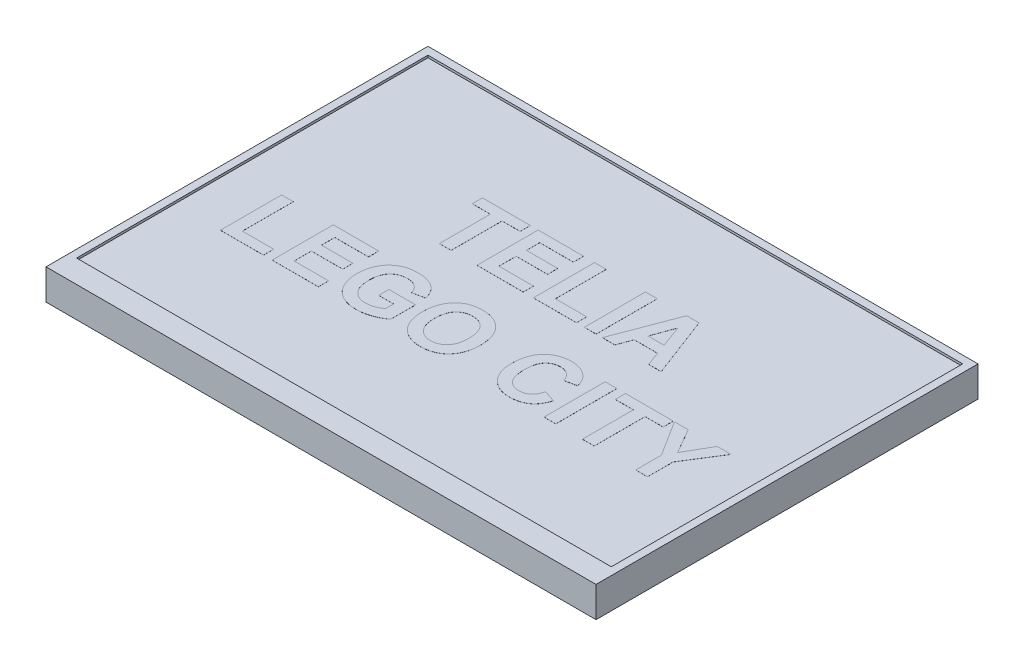
from build123d import *

# Parameters (mm, degrees)
SKETCH1_W           = 720
SKETCH1_H           = 500
BOSS_EXTRUDE1_DEPTH = 40
SKETCH2_W           = 700
SKETCH2_H           = 460
CUT_EXTRUDE1_DEPTH  = 3
SKETCH3_W           = 15.384615384
SKETCH3_H           = 80
SKETCH3_W_2         = 15.384615385
BOSS_EXTRUDE2_DEPTH = 0.1


with BuildPart() as part:
    # Sketch1 → Boss-Extrude1 (new body)
    with BuildSketch(Plane(origin=(0, 0, 0), x_dir=(1, 0, 0), z_dir=(0, 1, 0))):
        Rectangle(SKETCH1_W, SKETCH1_H)
    extrude(amount=BOSS_EXTRUDE1_DEPTH)

    # Sketch2 → Cut-Extrude1 (cut)
    with BuildSketch(Plane(origin=(0, 40, 0), x_dir=(1, 0, 0), z_dir=(0, 1, 0))):
        with Locations((0, 10)):
            Rectangle(SKETCH2_W, SKETCH2_H)
    extrude(amount=-CUT_EXTRUDE1_DEPTH, mode=Mode.SUBTRACT)

    # Sketch3 → Boss-Extrude2 (add)
    with BuildSketch(Plane(origin=(0, 37, 0), x_dir=(1, 0, 0), z_dir=(0, 1, 0))):
        Polygon((-131.794871795, 36.78780953), (-131.794871795, 103.454476196), (-155.384615385, 103.454476196), (-155.384615385, 116.78780953), (-92.820512821, 116.78780953), (-92.820512821, 103.454476196), (-116.41025641, 103.454476196), (-116.41025641, 36.78780953), align=None)
        Polygon((-82.564102564, 36.78780953), (-82.564102564, 116.78780953), (-23.076923077, 116.78780953), (-23.076923077, 103.454476196), (-67.179487179, 103.454476196), (-67.179487179, 86.018578761), (-26.153846154, 86.018578761), (-26.153846154, 72.685245427), (-67.179487179, 72.685245427), (-67.179487179, 50.121142863), (-22.051282051, 50.121142863), (-22.051282051, 36.78780953), align=None)
        Polygon((-8.717948718, 36.78780953), (-8.717948718, 116.78780953), (6.666666667, 116.78780953), (6.666666667, 50.121142863), (47.692307692, 50.121142863), (47.692307692, 36.78780953), align=None)
        with Locations((65.641025641, 76.78780953)):
            Rectangle(SKETCH3_W, SKETCH3_H)
        Polygon((158.461538462, 36.78780953), (142.147435897, 36.78780953), (135.400641026, 55.249347991), (104.695512821, 55.249347991), (97.948717949, 36.78780953), (81.538461538, 36.78780953), (111.778846154, 116.78780953), (128.076923077, 116.78780953), align=None)
        Polygon((130.512820513, 68.582681325), (120, 97.300630043), (109.519230769, 68.582681325), align=None, mode=Mode.SUBTRACT)
        Polygon((-290.256410256, -91.39167765), (-290.256410256, -11.39167765), (-274.871794872, -11.39167765), (-274.871794872, -78.058344316), (-233.846153846, -78.058344316), (-233.846153846, -91.39167765), align=None)
        Polygon((-222.564102564, -91.39167765), (-222.564102564, -11.39167765), (-163.076923077, -11.39167765), (-163.076923077, -24.725010983), (-207.179487179, -24.725010983), (-207.179487179, -42.160908419), (-166.153846154, -42.160908419), (-166.153846154, -55.494241752), (-207.179487179, -55.494241752), (-207.179487179, -78.058344316), (-162.051282051, -78.058344316), (-162.051282051, -91.39167765), align=None)
        with BuildLine():
            Line((-112.820512821, -61.648087906), (-112.820512821, -48.314754573))
            Line((-112.820512821, -48.314754573), (-77.948717949, -48.314754573))
            Line((-77.948717949, -48.314754573), (-77.948717949, -80.446164829))
            add(Edge.make_bspline(
                [(-77.948717949, -80.446164829), (-78.387588953, -80.841385134), (-79.284730078, -81.649295398), (-80.748716128, -82.788301933), (-82.359571985, -83.877201411), (-84.113983484, -84.931746637), (-85.996424546, -85.972536531), (-88.022146795, -86.96989818), (-90.196315106, -87.905457753), (-93.240000689, -89.1475945), (-97.186360379, -90.442028348), (-101.99725404, -91.588498601), (-106.849149891, -92.286681998), (-110.093934983, -92.373801468), (-111.71474359, -92.417318675)],
                knots=[0, 0, 0, 0, 0.001771395, 0.00362109, 0.005559067, 0.007601126, 0.009760072, 0.012010519, 0.01437157, 0.016859418, 0.021871449, 0.026811949, 0.031682399, 0.036543349, 0.036543349, 0.036543349, 0.036543349], degree=3))
            add(Edge.make_bspline(
                [(-111.71474359, -92.417318675), (-112.730152148, -92.402060035), (-114.731824423, -92.371980717), (-117.686748808, -92.129873694), (-120.539446606, -91.715629714), (-123.292242552, -91.129040359), (-125.954454646, -90.42192012), (-128.514985885, -89.519878819), (-130.964745565, -88.43705028), (-133.325928579, -87.230461507), (-135.554516769, -85.844596082), (-137.652663032, -84.328582969), (-139.605181332, -82.669235691), (-141.405071944, -80.863209462), (-143.076438101, -78.922942751), (-144.599778723, -76.839183168), (-145.965881588, -74.609525066), (-147.191609398, -72.261937072), (-148.282067348, -69.817065566), (-149.202222801, -67.294152925), (-150.008924634, -64.729829087), (-150.671945374, -62.115091282), (-151.15890168, -59.44143857), (-151.53745154, -56.721241772), (-151.740769537, -53.937504936), (-151.776715249, -52.065041936), (-151.794871795, -51.119241752)],
                knots=[0, 0, 0, 0, 0.003045926, 0.006004426, 0.00888726, 0.011687715, 0.014443986, 0.017145483, 0.019822197, 0.022474186, 0.025093631, 0.027686914, 0.030233429, 0.032771761, 0.035328692, 0.037909019, 0.040506409, 0.043165796, 0.045848979, 0.048531204, 0.051217591, 0.053911138, 0.056617385, 0.059366565, 0.062146817, 0.064984487, 0.064984487, 0.064984487, 0.064984487], degree=3))
            add(Edge.make_bspline(
                [(-151.794871795, -51.119241752), (-151.780147064, -50.098422477), (-151.751118255, -48.085946502), (-151.500930597, -45.111530404), (-151.11241876, -42.224275722), (-150.523265975, -39.429424141), (-149.806502281, -36.713965807), (-148.931732918, -34.07968898), (-147.859947368, -31.546111061), (-146.667683438, -29.091564395), (-145.310450407, -26.749992832), (-143.776853432, -24.551430861), (-142.112275797, -22.473703572), (-140.283824116, -20.549813915), (-138.297937308, -18.780699363), (-136.17480294, -17.146794745), (-133.919505436, -15.619933539), (-132.305328056, -14.759017355), (-131.490384615, -14.324369957)],
                knots=[0, 0, 0, 0, 0.003061946, 0.006036419, 0.008948724, 0.011796242, 0.014598943, 0.017371008, 0.020115092, 0.022845759, 0.025553144, 0.028224864, 0.030880338, 0.03353286, 0.036177285, 0.038850638, 0.041566358, 0.044335457, 0.044335457, 0.044335457, 0.044335457], degree=3))
            add(Edge.make_bspline(
                [(-131.490384615, -14.324369957), (-130.843642986, -14.003238666), (-129.530057668, -13.350994663), (-127.440137947, -12.572261151), (-125.254371351, -11.863689293), (-122.939757576, -11.335007784), (-120.512014689, -10.900655079), (-117.972218599, -10.576513868), (-115.312198451, -10.406294829), (-113.504493053, -10.379657529), (-112.580128205, -10.366036624)],
                knots=[0, 0, 0, 0, 0.002164826, 0.00439694, 0.006682771, 0.009053917, 0.011512168, 0.014080324, 0.016730425, 0.019503601, 0.019503601, 0.019503601, 0.019503601], degree=3))
            add(Edge.make_bspline(
                [(-112.580128205, -10.366036624), (-111.388328209, -10.383788597), (-109.070497579, -10.418312903), (-105.691274046, -10.705989207), (-102.510983114, -11.20178986), (-99.525195989, -11.884642284), (-96.740344999, -12.762609257), (-94.161224195, -13.841963625), (-91.772003551, -15.100983679), (-89.607288019, -16.590127438), (-87.623082655, -18.23208269), (-85.824565185, -20.028846671), (-84.211011695, -21.983080755), (-82.781354708, -24.084951761), (-81.546846576, -26.34314761), (-80.485405363, -28.737073045), (-79.611710743, -31.284901976), (-79.189473499, -33.054324018), (-78.974358974, -33.955780214)],
                knots=[0, 0, 0, 0, 0.003575011, 0.006952736, 0.010164468, 0.013223855, 0.016133027, 0.018912864, 0.021601401, 0.024219473, 0.026780218, 0.02931855, 0.031834167, 0.034372196, 0.03693274, 0.03954433, 0.04222018, 0.044999277, 0.044999277, 0.044999277, 0.044999277], degree=3))
            Line((-78.974358974, -33.955780214), (-94.358974359, -37.032703291))
            add(Edge.make_bspline(
                [(-94.358974359, -37.032703291), (-94.511311249, -36.52786343), (-94.81186909, -35.531823805), (-95.39452015, -34.102074595), (-96.065606245, -32.758015774), (-96.826737114, -31.489918891), (-97.685580572, -30.305590941), (-98.662886177, -29.217807276), (-99.697175627, -28.176949717), (-100.855997668, -27.255466686), (-102.091209354, -26.424753928), (-103.38889249, -25.675665927), (-104.778369197, -25.068176442), (-106.240176462, -24.579385067), (-107.767169576, -24.164272216), (-109.379276381, -23.908976219), (-111.058393221, -23.716433701), (-112.205595238, -23.705118794), (-112.788461538, -23.699369957)],
                knots=[0, 0, 0, 0, 0.001581269, 0.003119814, 0.00462486, 0.006084249, 0.007552324, 0.009005629, 0.010467481, 0.011949138, 0.013438143, 0.014930938, 0.016437689, 0.01797832, 0.019552589, 0.021178145, 0.022870046, 0.024617502, 0.024617502, 0.024617502, 0.024617502], degree=3))
            add(Edge.make_bspline(
                [(-112.788461538, -23.699369957), (-113.670650087, -23.722907036), (-115.392316211, -23.768841652), (-117.905719314, -24.068574894), (-120.276884559, -24.60182782), (-122.512012399, -25.337348557), (-124.615200484, -26.281440933), (-126.55802821, -27.469317606), (-128.388870833, -28.830690119), (-130.055628977, -30.42847871), (-131.567189238, -32.220056256), (-132.875715027, -34.226792461), (-133.965057143, -36.442200708), (-134.857290427, -38.855156789), (-135.567698493, -41.4657613), (-136.049630335, -44.283255853), (-136.364515831, -47.303318075), (-136.39469664, -49.38762322), (-136.41025641, -50.46219047)],
                knots=[0, 0, 0, 0, 0.002646609, 0.005165083, 0.007579483, 0.009925858, 0.012213712, 0.014478379, 0.016744407, 0.019045468, 0.021388721, 0.023762302, 0.026213387, 0.028779292, 0.0314695, 0.03431765, 0.037345817, 0.040568406, 0.040568406, 0.040568406, 0.040568406], degree=3))
            add(Edge.make_bspline(
                [(-136.41025641, -50.46219047), (-136.39403074, -51.616738414), (-136.362495203, -53.860669741), (-136.055863559, -57.111981186), (-135.551451829, -60.141167771), (-134.827959887, -62.944408614), (-133.917581702, -65.531649195), (-132.823266419, -67.911154557), (-131.472749106, -70.038770327), (-129.951506806, -71.957143992), (-128.251222093, -73.633406878), (-126.419574288, -75.094818588), (-124.466760932, -76.333312013), (-122.374774144, -77.329337897), (-120.169998631, -78.122200159), (-117.832165098, -78.678051655), (-115.368234604, -79.023326132), (-113.681719932, -79.063480692), (-112.820512821, -79.083985342)],
                knots=[0, 0, 0, 0, 0.003462874, 0.006730297, 0.00978645, 0.012666655, 0.015403711, 0.018006089, 0.020504908, 0.022945124, 0.025336169, 0.02765125, 0.029963223, 0.032256906, 0.034588623, 0.036979077, 0.039453989, 0.042036554, 0.042036554, 0.042036554, 0.042036554], degree=3))
            add(Edge.make_bspline(
                [(-112.820512821, -79.083985342), (-111.948238001, -79.059738836), (-110.195343851, -79.011013874), (-107.569833902, -78.598119121), (-104.934051389, -77.990531213), (-102.349855271, -77.073973562), (-99.840166286, -76.022688379), (-97.49710359, -74.811100784), (-95.302897566, -73.548179504), (-93.981729934, -72.563860022), (-93.333333333, -72.080780214)],
                knots=[0, 0, 0, 0, 0.002615324, 0.005255667, 0.007957164, 0.010719205, 0.013469506, 0.016114174, 0.018628974, 0.021052664, 0.021052664, 0.021052664, 0.021052664], degree=3))
            Line((-93.333333333, -72.080780214), (-93.333333333, -61.648087906))
            Line((-93.333333333, -61.648087906), (-112.820512821, -61.648087906))
        make_face()
        with BuildLine():
            add(Edge.make_bspline(
                [(-65.641025641, -51.87244688), (-65.635364368, -50.883839897), (-65.624246358, -48.942343393), (-65.43159705, -46.094095135), (-65.177670254, -43.36394283), (-64.764150876, -40.762625178), (-64.277701115, -38.277967119), (-63.669281571, -35.910706181), (-62.93635147, -33.669144284), (-62.353299774, -32.237931241), (-62.067307692, -31.535908419)],
                knots=[0, 0, 0, 0, 0.002965133, 0.005823139, 0.008561086, 0.011187972, 0.013721138, 0.016154346, 0.01851594, 0.020789549, 0.020789549, 0.020789549, 0.020789549], degree=3))
            add(Edge.make_bspline(
                [(-62.067307692, -31.535908419), (-61.599819175, -30.537901661), (-60.67034057, -28.553626336), (-58.944152715, -25.749685784), (-56.987620558, -23.105342656), (-54.816851694, -20.634459684), (-52.487266538, -18.374234629), (-49.987875189, -16.439807425), (-47.407473519, -14.765848358), (-45.572222113, -13.923946441), (-44.663461538, -13.507062265)],
                knots=[0, 0, 0, 0, 0.003304004, 0.006569147, 0.009857685, 0.013162272, 0.01642655, 0.019577779, 0.022632125, 0.02562802, 0.02562802, 0.02562802, 0.02562802], degree=3))
            add(Edge.make_bspline(
                [(-44.663461538, -13.507062265), (-44.046598264, -13.254038714), (-42.799760302, -12.742613603), (-40.862027345, -12.104328266), (-38.85077132, -11.585750281), (-36.780539512, -11.122201983), (-34.631231701, -10.802570178), (-32.420215191, -10.534569898), (-30.13538984, -10.394106288), (-28.589905002, -10.37549494), (-27.804487179, -10.366036624)],
                knots=[0, 0, 0, 0, 0.001999805, 0.004042115, 0.006113953, 0.008229398, 0.010403044, 0.012629398, 0.014909605, 0.017265864, 0.017265864, 0.017265864, 0.017265864], degree=3))
            add(Edge.make_bspline(
                [(-27.804487179, -10.366036624), (-26.398135746, -10.401289237), (-23.645886662, -10.470279084), (-19.625623621, -10.968584547), (-15.821234136, -11.810019195), (-12.24559613, -13.026204146), (-8.867881556, -14.546461731), (-5.714333251, -16.432168145), (-2.780283892, -18.662914279), (-0.07140045, -21.208109441), (2.368143117, -24.063317999), (4.492782893, -27.201868037), (6.275068423, -30.609052028), (7.742883463, -34.275469395), (8.870788714, -38.21309581), (9.685699212, -42.410820875), (10.169822019, -46.87173655), (10.227029815, -49.932122298), (10.256410256, -51.503857137)],
                knots=[0, 0, 0, 0, 0.004218428, 0.008255523, 0.012131774, 0.015887009, 0.019566142, 0.023224238, 0.026884545, 0.030603115, 0.034354211, 0.038127866, 0.041948629, 0.045867873, 0.0499557, 0.054217496, 0.058682557, 0.06339682, 0.06339682, 0.06339682, 0.06339682], degree=3))
            add(Edge.make_bspline(
                [(10.256410256, -51.503857137), (10.227708413, -53.065067418), (10.171831287, -56.104452157), (9.67867203, -60.530362837), (8.897546521, -64.697486364), (7.742350455, -68.596303514), (6.318343536, -72.256564863), (4.517717843, -75.634673779), (2.437574432, -78.775438654), (0.00149579, -81.599880102), (-2.661795606, -84.159682147), (-5.592123271, -86.364356469), (-8.722715296, -88.252617917), (-12.082013936, -89.777268804), (-15.6481239, -90.968406858), (-19.43268295, -91.816307314), (-23.437632087, -92.312695232), (-26.179157548, -92.381935571), (-27.580128205, -92.417318675)],
                knots=[0, 0, 0, 0, 0.00468223, 0.009115428, 0.013342705, 0.017384377, 0.021297686, 0.025104274, 0.028846733, 0.032575235, 0.036270527, 0.039908383, 0.043552728, 0.047217277, 0.050952214, 0.054812831, 0.058834021, 0.063036438, 0.063036438, 0.063036438, 0.063036438], degree=3))
            add(Edge.make_bspline(
                [(-27.580128205, -92.417318675), (-28.997101622, -92.38185392), (-31.770525671, -92.312439205), (-35.818191324, -91.817562257), (-39.640318564, -90.969382691), (-43.234185689, -89.774054796), (-46.624303529, -88.272565203), (-49.779372442, -86.403599064), (-52.701136461, -84.184962138), (-55.386681219, -81.655291209), (-57.821253543, -78.839153661), (-59.89844342, -75.71858303), (-61.699163028, -72.373469798), (-63.130656675, -68.75314351), (-64.279491495, -64.894852684), (-65.062525747, -60.776396399), (-65.556638602, -56.409109746), (-65.612382485, -53.412308263), (-65.641025641, -51.87244688)],
                knots=[0, 0, 0, 0, 0.004250452, 0.008319356, 0.012211244, 0.015976588, 0.01966374, 0.023313647, 0.026951503, 0.030647421, 0.034363746, 0.038092902, 0.041871183, 0.04573984, 0.049750767, 0.053930849, 0.058300328, 0.062918494, 0.062918494, 0.062918494, 0.062918494], degree=3))
        make_face()
        with BuildLine():
            add(Edge.make_bspline(
                [(-50.256410256, -51.343600727), (-50.241041218, -52.450212079), (-50.211279367, -54.59314391), (-49.894276253, -57.703557594), (-49.41319853, -60.611358172), (-48.705703069, -63.313245357), (-47.811917217, -65.811173766), (-46.71684426, -68.107232884), (-45.425009708, -70.204842465), (-43.903000185, -72.059719004), (-42.256305221, -73.715766219), (-40.478844915, -75.148664719), (-38.603744872, -76.381969194), (-36.598560176, -77.355658905), (-34.505022297, -78.128388219), (-32.306865918, -78.701338707), (-29.993161279, -79.015944792), (-28.414353454, -79.061061875), (-27.612179487, -79.083985342)],
                knots=[0, 0, 0, 0, 0.003318701, 0.006426601, 0.009369478, 0.012152592, 0.014793713, 0.017316823, 0.019771468, 0.022164177, 0.024498536, 0.026766094, 0.029001943, 0.031216557, 0.033437366, 0.035687871, 0.038017715, 0.040424177, 0.040424177, 0.040424177, 0.040424177], degree=3))
            add(Edge.make_bspline(
                [(-27.612179487, -79.083985342), (-26.809897454, -79.061526339), (-25.230876937, -79.017323396), (-22.92001514, -78.696284763), (-20.717502597, -78.147892151), (-18.632281728, -77.379122628), (-16.654848384, -76.38997191), (-14.786924925, -75.184315532), (-13.039278525, -73.744897969), (-11.394375967, -72.11290898), (-9.913449139, -70.245712546), (-8.632613509, -68.148464951), (-7.538080087, -65.838480167), (-6.64420011, -63.314894021), (-5.954116265, -60.572958426), (-5.492672494, -57.61122261), (-5.173105952, -54.4381551), (-5.143465484, -52.247234388), (-5.128205128, -51.119241752)],
                knots=[0, 0, 0, 0, 0.002406462, 0.004736306, 0.00698287, 0.009203679, 0.011389579, 0.013603265, 0.015858386, 0.018170082, 0.020542743, 0.02298895, 0.025526524, 0.028197811, 0.03100797, 0.033995624, 0.037183277, 0.040566054, 0.040566054, 0.040566054, 0.040566054], degree=3))
            add(Edge.make_bspline(
                [(-5.128205128, -51.119241752), (-5.145441894, -50.002140488), (-5.178822529, -47.838767737), (-5.469533373, -44.705757215), (-5.945664018, -41.790971464), (-6.607538228, -39.095165569), (-7.482246585, -36.617905138), (-8.526983344, -34.352415859), (-9.790218478, -32.310533663), (-11.238994388, -30.4933158), (-12.842131648, -28.893813719), (-14.572393495, -27.49351817), (-16.43961066, -26.328387149), (-18.425559415, -25.348087466), (-20.550915546, -24.620806707), (-22.79408047, -24.090334254), (-25.161402184, -23.763668502), (-26.783135864, -23.721120729), (-27.612179487, -23.699369957)],
                knots=[0, 0, 0, 0, 0.003350739, 0.006489024, 0.009429238, 0.012204405, 0.014804563, 0.017299472, 0.019674297, 0.021989378, 0.024255746, 0.0264557, 0.028652148, 0.03084532, 0.033085473, 0.035374953, 0.037752426, 0.040238932, 0.040238932, 0.040238932, 0.040238932], degree=3))
            add(Edge.make_bspline(
                [(-27.612179487, -23.699369957), (-28.441327899, -23.720786158), (-30.06326656, -23.76267946), (-32.434278385, -24.094753627), (-34.684509997, -24.609419355), (-36.809565734, -25.378227933), (-38.81281273, -26.34911363), (-40.686841529, -27.553205409), (-42.446418889, -28.951124538), (-44.063919791, -30.574878744), (-45.536170434, -32.408009752), (-46.800013904, -34.47484167), (-47.877718129, -36.752802122), (-48.76191197, -39.248634075), (-49.417373023, -41.96920341), (-49.921149401, -44.896226247), (-50.204051531, -48.047418646), (-50.238582238, -50.221258771), (-50.256410256, -51.343600727)],
                knots=[0, 0, 0, 0, 0.002486506, 0.004863979, 0.007169055, 0.009399442, 0.011628446, 0.013833472, 0.01606846, 0.018357492, 0.020695094, 0.023105608, 0.025607354, 0.028243073, 0.03103379, 0.033992463, 0.037146707, 0.040513465, 0.040513465, 0.040513465, 0.040513465], degree=3))
        make_face(mode=Mode.SUBTRACT)
        with BuildLine():
            Line((105.641025641, -61.648087906), (121.025641026, -66.776293034))
            add(Edge.make_bspline(
                [(121.025641026, -66.776293034), (120.712978289, -67.785023511), (120.100686294, -69.760435105), (118.976415543, -72.591668974), (117.690829379, -75.215502478), (116.290160316, -77.662645847), (114.687303518, -79.869881437), (112.971995416, -81.910289499), (111.093233054, -83.740895146), (109.060286767, -85.365607389), (106.8927248, -86.802375779), (104.565368606, -88.017006095), (102.112950687, -89.063135712), (99.510602137, -89.910721261), (96.775593895, -90.589508632), (93.895093119, -91.037851378), (90.882574497, -91.341842571), (88.825583498, -91.374802616), (87.772435897, -91.39167765)],
                knots=[0, 0, 0, 0, 0.003167447, 0.006202857, 0.009127087, 0.011927908, 0.014649674, 0.017298756, 0.019916632, 0.022504512, 0.025095815, 0.02770519, 0.030369209, 0.033085544, 0.035907376, 0.038813369, 0.041824015, 0.04498253, 0.04498253, 0.04498253, 0.04498253], degree=3))
            add(Edge.make_bspline(
                [(87.772435897, -91.39167765), (86.472540384, -91.36479863), (83.91560704, -91.311926795), (80.176334206, -90.779698766), (76.612976273, -89.949296123), (73.220435629, -88.799618111), (70.021357008, -87.276872504), (66.986553919, -85.443684201), (64.138112559, -83.262836508), (61.486025736, -80.771085112), (59.076540736, -77.987451831), (56.992959542, -74.926978622), (55.212611462, -71.632780129), (53.773642349, -68.089149217), (52.648465604, -64.299724585), (51.860276961, -60.269745716), (51.367078629, -55.997943165), (51.310888931, -53.070421147), (51.282051282, -51.567959701)],
                knots=[0, 0, 0, 0, 0.003897527, 0.007666552, 0.011304937, 0.014862629, 0.018389618, 0.021913073, 0.025480497, 0.029131109, 0.032812684, 0.036502063, 0.04021628, 0.044025531, 0.047955083, 0.052056551, 0.056330473, 0.060836528, 0.060836528, 0.060836528, 0.060836528], degree=3))
            add(Edge.make_bspline(
                [(51.282051282, -51.567959701), (51.310758948, -49.985391096), (51.366762366, -46.898088505), (51.860884644, -42.409414852), (52.627980053, -38.179101607), (53.755058502, -34.233378398), (55.172881742, -30.544476587), (56.955391353, -27.149015619), (59.01818889, -24.00172472), (61.416738482, -21.160289865), (64.080911868, -18.637479938), (66.935903166, -16.406633928), (70.008346882, -14.53511407), (73.281429912, -13.00468306), (76.759542036, -11.820360225), (80.435839277, -10.967554825), (84.313329497, -10.471167245), (86.964388802, -10.401559595), (88.317307692, -10.366036624)],
                knots=[0, 0, 0, 0, 0.004746296, 0.009259157, 0.013530675, 0.017629481, 0.021551837, 0.025365165, 0.029112082, 0.032819862, 0.036492497, 0.040101933, 0.043669429, 0.047261247, 0.050920291, 0.054671557, 0.058565557, 0.062623875, 0.062623875, 0.062623875, 0.062623875], degree=3))
            add(Edge.make_bspline(
                [(88.317307692, -10.366036624), (89.49886404, -10.39580878), (91.815462499, -10.454181053), (95.207885703, -10.850764427), (98.422953524, -11.546741773), (101.478044447, -12.486156424), (104.355767216, -13.725933861), (107.061277259, -15.240929123), (109.603874068, -17.023126326), (111.135840991, -18.415233425), (111.907051282, -19.116036624)],
                knots=[0, 0, 0, 0, 0.003544602, 0.006949664, 0.010228034, 0.01340103, 0.01652377, 0.019608861, 0.022690205, 0.02581389, 0.02581389, 0.02581389, 0.02581389], degree=3))
            add(Edge.make_bspline(
                [(111.907051282, -19.116036624), (112.354034642, -19.561964817), (113.258500676, -20.46429573), (114.466216696, -21.987685985), (115.611281521, -23.627615854), (116.675520688, -25.412060447), (117.62529826, -27.354504818), (118.506318404, -29.425119208), (119.317440598, -31.631885134), (119.768517812, -33.167657867), (120, -33.955780214)],
                knots=[0, 0, 0, 0, 0.001892723, 0.003829904, 0.005821537, 0.00789108, 0.010055491, 0.012302855, 0.014640017, 0.017103696, 0.017103696, 0.017103696, 0.017103696], degree=3))
            Line((120, -33.955780214), (104.615384615, -37.032703291))
            add(Edge.make_bspline(
                [(104.615384615, -37.032703291), (104.484621709, -36.528087014), (104.227053091, -35.534125342), (103.70589804, -34.105857003), (103.108092107, -32.75055791), (102.367166401, -31.501424068), (101.580111709, -30.302885032), (100.648283361, -29.208159652), (99.631191204, -28.18855758), (98.521508255, -27.254659804), (97.332463526, -26.425337176), (96.086950349, -25.679827785), (94.762331009, -25.071259171), (93.376226202, -24.578928588), (91.934156669, -24.166146489), (90.423283572, -23.91115175), (88.856583535, -23.715398197), (87.789135295, -23.704791017), (87.243589744, -23.699369957)],
                knots=[0, 0, 0, 0, 0.001562972, 0.003078646, 0.004556137, 0.005999246, 0.007430471, 0.008852425, 0.0103029, 0.011747432, 0.013196845, 0.014648028, 0.016096377, 0.017561387, 0.019058306, 0.020589153, 0.022153604, 0.023788926, 0.023788926, 0.023788926, 0.023788926], degree=3))
            add(Edge.make_bspline(
                [(87.243589744, -23.699369957), (86.4943841, -23.714500497), (85.032158866, -23.744030783), (82.89489265, -24.073273475), (80.857835037, -24.53276572), (78.929201355, -25.234408002), (77.120935143, -26.131802681), (75.412485336, -27.222686257), (73.813228825, -28.502386219), (72.322625086, -29.98606279), (70.985010837, -31.700541575), (69.809056982, -33.649362361), (68.833497846, -35.854650553), (68.041498969, -38.294765356), (67.418105626, -40.975509368), (66.972953702, -43.900320808), (66.726771305, -47.071200519), (66.687133871, -49.265195593), (66.666666667, -50.398087906)],
                knots=[0, 0, 0, 0, 0.002245649, 0.004382835, 0.006474105, 0.008501839, 0.010522913, 0.01251899, 0.014571274, 0.016656332, 0.01881385, 0.021078518, 0.023467198, 0.026031501, 0.02876419, 0.031715172, 0.034898592, 0.038297388, 0.038297388, 0.038297388, 0.038297388], degree=3))
            add(Edge.make_bspline(
                [(66.666666667, -50.398087906), (66.686932336, -51.600399852), (66.725981159, -53.917069774), (66.972111323, -57.258651866), (67.42010979, -60.332023386), (68.03521825, -63.142638483), (68.831208296, -65.688775635), (69.805117661, -67.966028782), (70.962910039, -69.977064854), (72.302784141, -71.720544737), (73.79086566, -73.21818858), (75.386851034, -74.505821305), (77.081324269, -75.606742207), (78.884481953, -76.512508942), (80.803182325, -77.197711399), (82.821656497, -77.694632233), (84.947310585, -78.010532704), (86.403782224, -78.042183745), (87.147435897, -78.058344316)],
                knots=[0, 0, 0, 0, 0.003607051, 0.006950232, 0.010043845, 0.012917131, 0.015572943, 0.018034953, 0.020332831, 0.022515674, 0.024612095, 0.026651889, 0.028656632, 0.030663359, 0.032691094, 0.034754982, 0.036892168, 0.039121807, 0.039121807, 0.039121807, 0.039121807], degree=3))
            add(Edge.make_bspline(
                [(87.147435897, -78.058344316), (87.698009949, -78.044608364), (88.780632083, -78.017598654), (90.380831064, -77.846170086), (91.916695733, -77.519023375), (93.395743667, -77.08643106), (94.823721439, -76.543655322), (96.178847721, -75.847383193), (97.48778402, -75.047121785), (98.723370954, -74.109276737), (99.902153658, -73.056366607), (100.977273433, -71.839464911), (101.974536275, -70.487811042), (102.881290415, -68.992371872), (103.727833382, -67.365947818), (104.44807645, -65.583198321), (105.119047423, -63.672933447), (105.463993898, -62.334825249), (105.641025641, -61.648087906)],
                knots=[0, 0, 0, 0, 0.001651885, 0.003248187, 0.004819681, 0.006356221, 0.007868077, 0.009394641, 0.01092011, 0.012464985, 0.014042107, 0.01565378, 0.017326906, 0.01907495, 0.020895465, 0.022821011, 0.024838079, 0.026964664, 0.026964664, 0.026964664, 0.026964664], degree=3))
        make_face()
        with Locations((141.025641026, -51.39167765)):
            Rectangle(SKETCH3_W_2, SKETCH3_H)
        Polygon((183.58974359, -91.39167765), (183.58974359, -24.725010983), (160, -24.725010983), (160, -11.39167765), (222.564102564, -11.39167765), (222.564102564, -24.725010983), (198.974358974, -24.725010983), (198.974358974, -91.39167765), align=None)
        Polygon((253.333333333, -91.39167765), (253.333333333, -57.721805855), (224.102564103, -11.39167765), (242.099358974, -11.39167765), (261.009615385, -44.356421239), (279.951923077, -11.39167765), (297.948717949, -11.39167765), (268.717948718, -57.833985342), (268.717948718, -91.39167765), align=None)
    extrude(amount=BOSS_EXTRUDE2_DEPTH)


solid = part.part
